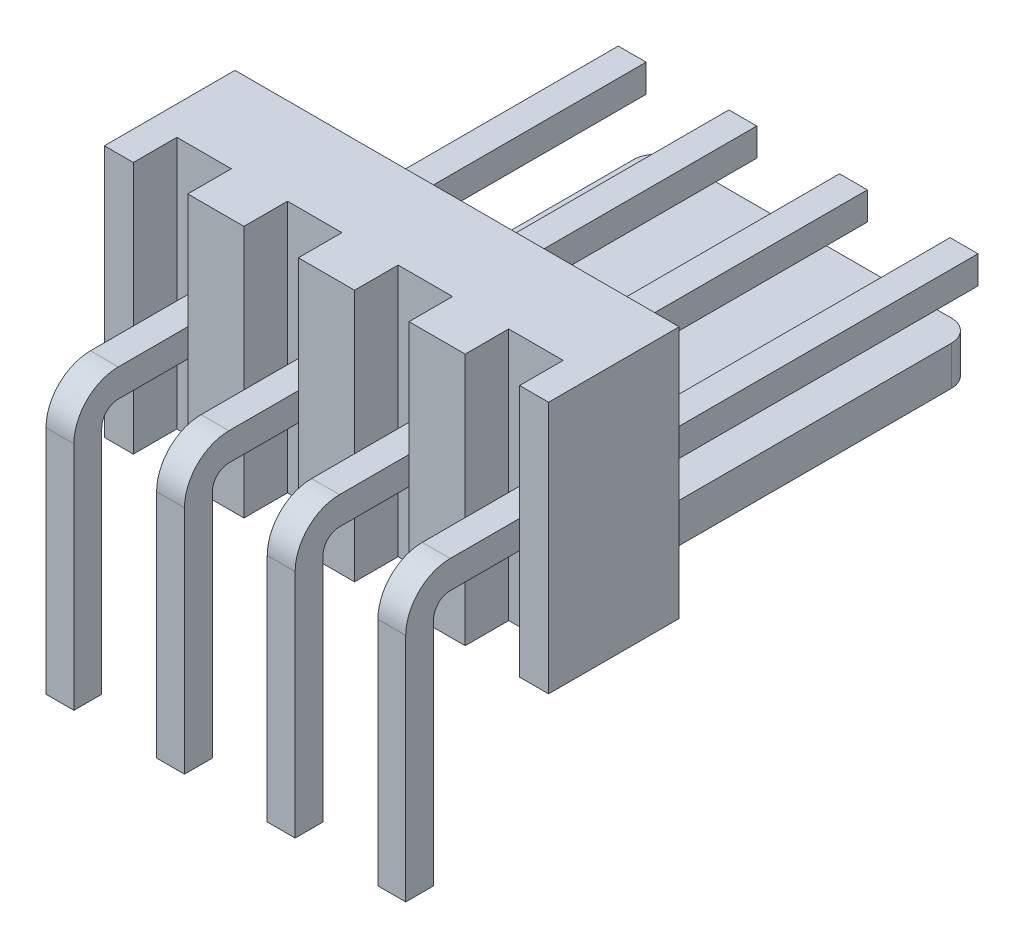
from build123d import *

# Parameters (mm, degrees)
SCHIZZO1_W                   = 10.2
SCHIZZO1_H                   = 5.8
ESTRUSIONE_ESTRUSIONE1_DEPTH = 3
TAGLIO_ESTRUSIONE1_DEPTH     = 6.8
SCHIZZO3_W                   = 7.3
SCHIZZO3_H                   = 0.9
ESTRUSIONE_ESTRUSIONE2_DEPTH = 8.2
RACCORDO1_R                  = 0.5
ESTRUSIONE_ESTRUSIONE3_DEPTH = 0.32
RIPETIZIONE_A_L1_COUNT       = 3
RIPETIZIONE_A_L1_PITCH       = 2.54
RIPETIZIONE_A_L1_COL_COUNT   = 2
RIPETIZIONE_A_L1_COL_PITCH   = 2.54
SMUSSO1_SIZE                 = 0.18


with BuildPart() as part:
    # Schizzo1 → Estrusione-Estrusione1 (new body)
    with BuildSketch(Plane.XY):
        Rectangle(SCHIZZO1_W, SCHIZZO1_H)
    extrude(amount=ESTRUSIONE_ESTRUSIONE1_DEPTH)

    # Schizzo2 → Taglio-Estrusione1 (cut, through all)
    with BuildSketch(Plane(origin=(0, 2.9, 0), x_dir=(1, 0, 0), z_dir=(0, 1, 0))):
        Polygon((-4.435, -3), (-4.435, -2), (-3.185, -2), (-3.185, -3), (-1.895, -3), (-1.895, -2), (-0.645, -2), (-0.645, -3), (0.645, -3), (0.645, -2), (1.895, -2), (1.895, -3), (3.185, -3), (3.185, -2), (4.435, -2), (4.435, -3), (4.435, -3.561285121), (-4.435, -3.561285121), align=None)
    extrude(amount=-TAGLIO_ESTRUSIONE1_DEPTH, mode=Mode.SUBTRACT)

    # Schizzo3 → Estrusione-Estrusione2 (add)
    with BuildSketch(Plane(origin=(0, 0, 0), x_dir=(-1, 0, 0), z_dir=(0, 0, -1))):
        with Locations((0, -2.45)):
            Rectangle(SCHIZZO3_W, SCHIZZO3_H)
    extrude(amount=ESTRUSIONE_ESTRUSIONE2_DEPTH)

    # Raccordo1
    raccordo1_edges = [part.edges().sort_by_distance(p)[0] for p in [
        (-3.65, -2.45, -8.2),
        (3.65, -2.45, -8.2),
    ]]
    fillet(raccordo1_edges, radius=RACCORDO1_R)

    # Schizzo5 → Estrusione-Estrusione3 (add, symmetric)
    with BuildSketch(Plane(origin=(1.28, 0, 0), x_dir=(0, 0, -1), z_dir=(1, 0, 0))):
        with BuildLine():
            Line((-4.3, -0.037), (8, -0.037))
            Line((8, -0.037), (8, -0.677))
            Line((8, -0.677), (-4.3, -0.677))
            ThreePointArc((-4.3, -0.677), (-4.568700577, -0.788299423), (-4.68, -1.057))
            Line((-4.68, -1.057), (-4.68, -6.357))
            Line((-4.68, -6.357), (-5.32, -6.357))
            Line((-5.32, -6.357), (-5.32, -1.057))
            ThreePointArc((-5.32, -1.057), (-5.021248917, -0.335751083), (-4.3, -0.037))
        make_face()
    estrusione_estrusione3 = extrude(amount=ESTRUSIONE_ESTRUSIONE3_DEPTH, both=True)

    # Ripetizione a L1: Estrusione-Estrusione3 ×3
    with Locations(*[(-i * RIPETIZIONE_A_L1_PITCH, 0, 0) for i in range(1, RIPETIZIONE_A_L1_COUNT)]):
        add(estrusione_estrusione3)

    # Ripetizione a L1 col: Estrusione-Estrusione3 ×2
    with Locations(*[(i * RIPETIZIONE_A_L1_COL_PITCH, 0, 0) for i in range(1, RIPETIZIONE_A_L1_COL_COUNT)]):
        add(estrusione_estrusione3)

    # Smusso1
    smusso1_edges = [part.edges().sort_by_distance(p)[0] for p in [
        (0.96, -0.357, -8),
        (1.28, -0.677, -8),
        (1.28, -0.037, -8),
        (1.6, -0.357, -8),
        (3.5, -0.357, -8),
        (3.82, -0.677, -8),
        (3.82, -0.037, -8),
        (4.14, -0.357, -8),
        (-1.58, -0.357, -8),
        (-1.26, -0.677, -8),
        (-1.26, -0.037, -8),
        (-0.94, -0.357, -8),
        (-4.12, -0.357, -8),
        (-3.8, -0.677, -8),
        (-3.8, -0.037, -8),
        (-3.48, -0.357, -8),
    ]]
    chamfer(smusso1_edges, length=SMUSSO1_SIZE)


solid = part.part
